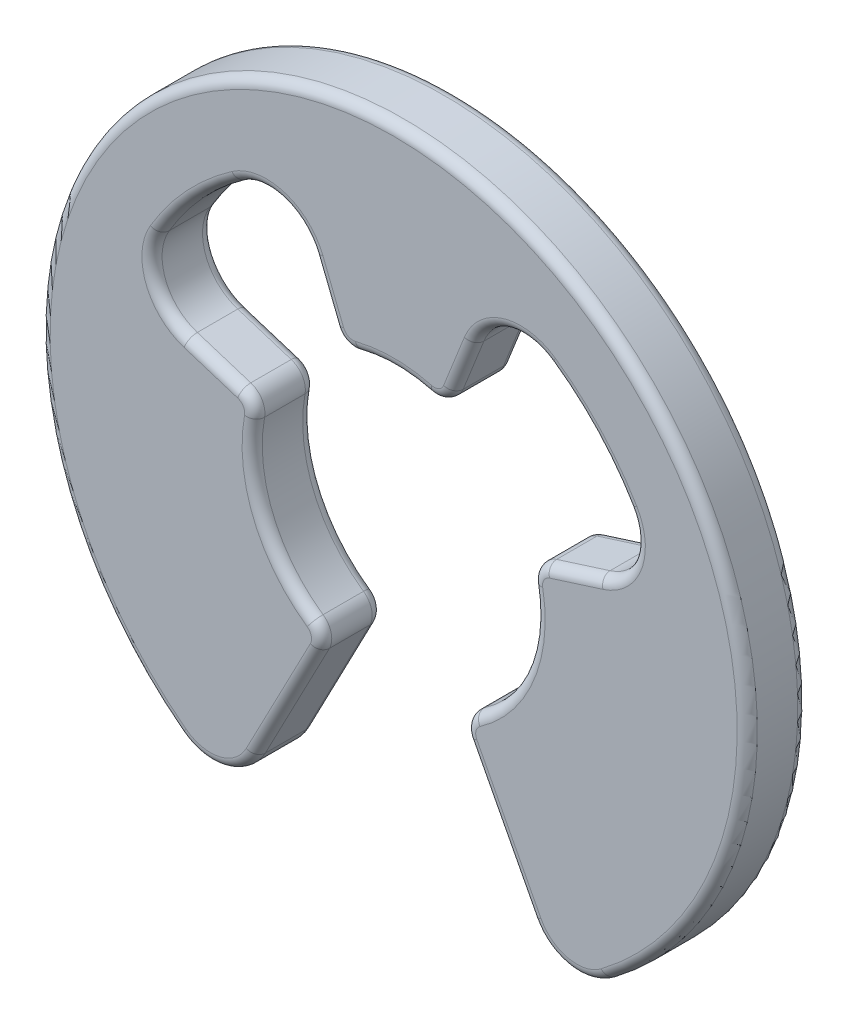
from build123d import *

# Parameters (mm, degrees)
EXTRUDE_1_DEPTH = 0.6
FILLET_1_R      = 0.2
FILLET_2_R      = 0.5
FILLET_3_R      = 0.1


with BuildPart() as part:
    # 草图1 → 凸台-拉伸1 (new body)
    with BuildSketch(Plane.XY):
        with BuildLine():
            Line((-0.518518519, 1.300437829), (-1, 2.507987241))
            ThreePointArc((-1, 2.507987241), (-1.977224027, 1.838636764), (-2.573921428, 0.815431471))
            Line((-2.573921428, 0.815431471), (-1.334625926, 0.422816318))
            ThreePointArc((-1.334625926, 0.422816318), (-1.294163864, -0.533984917), (-0.648148148, -1.240928676))
            Line((-0.648148148, -1.240928676), (-1.62037037, -3.102321689))
            ThreePointArc((-1.62037037, -3.102321689), (0, 3.5), (1.62037037, -3.102321689))
            Line((1.62037037, -3.102321689), (0.648148148, -1.240928676))
            ThreePointArc((0.648148148, -1.240928676), (1.294163864, -0.533984917), (1.334625926, 0.422816318))
            Line((1.334625926, 0.422816318), (2.573921428, 0.815431471))
            ThreePointArc((2.573921428, 0.815431471), (1.977224027, 1.838636764), (1, 2.507987241))
            Line((1, 2.507987241), (0.518518519, 1.300437829))
            ThreePointArc((0.518518519, 1.300437829), (0, 1.4), (-0.518518519, 1.300437829))
        make_face()
    extrude(amount=EXTRUDE_1_DEPTH)

    # 圆角1
    fillet_1_edges = [part.edges().sort_by_distance(p)[0] for p in [
        (0.518518519, 1.300437829, 0.3),
        (-0.518518519, 1.300437829, 0.3),
        (-1.334625926, 0.422816318, 0.3),
        (-0.648148148, -1.240928676, 0.3),
        (0.648148148, -1.240928676, 0.3),
        (1.334625926, 0.422816318, 0.3),
    ]]
    fillet(fillet_1_edges, radius=FILLET_1_R)

    # 圆角2
    fillet_2_edges = [part.edges().sort_by_distance(p)[0] for p in [
        (1, 2.507987241, 0.3),
        (-1, 2.507987241, 0.3),
        (-2.573921428, 0.815431471, 0.3),
        (-1.62037037, -3.102321689, 0.3),
        (1.62037037, -3.102321689, 0.3),
        (2.573921428, 0.815431471, 0.3),
    ]]
    fillet(fillet_2_edges, radius=FILLET_2_R)

    # 圆角3
    fillet_3_edges = [part.edges().sort_by_distance(p)[0] for p in [
        (1.052196916, -2.014510617, 0),
        (1.052196916, -2.014510617, 0.6),
        (0.690718392, 1.732312913, 0),
        (0, 1.4, 0),
        (-1.777854869, 0.563233514, 0),
        (-1.294163864, -0.533984917, 0),
        (1.294163864, -0.533984917, 0),
        (-0.718005558, -1.266675972, 0),
        (-1.40231384, 0.391811042, 0),
        (-0.492505133, 1.37019659, 0),
        (0.492505133, 1.37019659, 0),
        (1.40231384, 0.391811042, 0),
        (0.718005558, -1.266675972, 0),
        (1.294163864, -0.533984917, 0.6),
        (-1.294163864, -0.533984917, 0.6),
        (-1.777854869, 0.563233514, 0.6),
        (0, 1.4, 0.6),
        (0.690718392, 1.732312913, 0.6),
        (-0.718005558, -1.266675972, 0.6),
        (-1.40231384, 0.391811042, 0.6),
        (-0.492505133, 1.37019659, 0.6),
        (0.492505133, 1.37019659, 0.6),
        (1.40231384, 0.391811042, 0.6),
        (0.718005558, -1.266675972, 0.6),
        (0, 3.5, 0),
        (0, 3.5, 0.6),
        (1.777854869, 0.563233514, 0),
        (1.977224027, 1.838636764, 0),
        (-0.690718392, 1.732312913, 0),
        (-1.977224027, 1.838636764, 0),
        (-1.052196916, -2.014510617, 0),
        (-1.703371479, -2.878370594, 0),
        (1.703371479, -2.878370594, 0),
        (-1.052196916, -2.014510617, 0.6),
        (-1.977224027, 1.838636764, 0.6),
        (-0.690718392, 1.732312913, 0.6),
        (1.977224027, 1.838636764, 0.6),
        (1.777854869, 0.563233514, 0.6),
        (-1.703371479, -2.878370594, 0.6),
        (1.703371479, -2.878370594, 0.6),
        (2.358627968, 0.94570267, 0),
        (2.358627968, 0.94570267, 0.6),
        (1.114310209, 2.283810892, 0),
        (1.114310209, 2.283810892, 0.6),
        (-2.358627968, 0.94570267, 0),
        (-2.358627968, 0.94570267, 0.6),
        (-1.114310209, 2.283810892, 0),
        (-1.114310209, 2.283810892, 0.6),
    ]]
    fillet(fillet_3_edges, radius=FILLET_3_R)


solid = part.part
